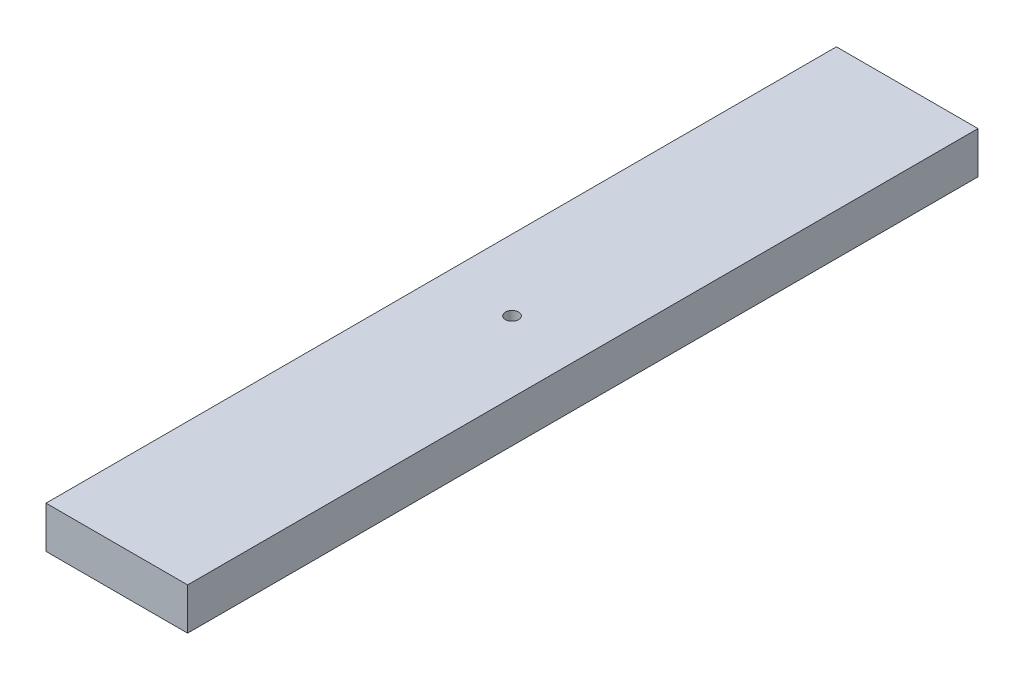
from build123d import *

# Parameters (mm, degrees)
SKETCH2_W           = 21.5
SKETCH2_H           = 120
SKETCH2_R           = 1
BOSS_EXTRUDE1_DEPTH = 6.35


with BuildPart() as part:
    # Sketch2 → Boss-Extrude1 (new body)
    with BuildSketch(Plane(origin=(0, 0, 0), x_dir=(1, 0, 0), z_dir=(0, 1, 0))):
        Rectangle(SKETCH2_W, SKETCH2_H)
        Circle(SKETCH2_R, mode=Mode.SUBTRACT)
    extrude(amount=BOSS_EXTRUDE1_DEPTH)


solid = part.part
